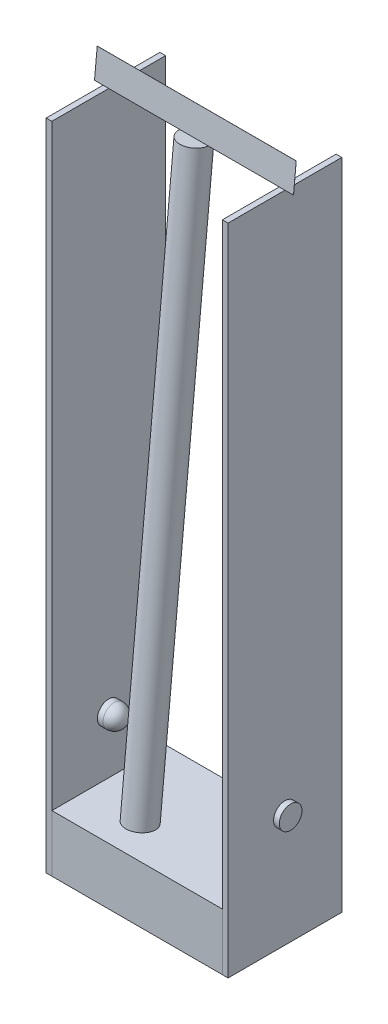
from build123d import *

# Parameters (mm, degrees)
SKETCH1_W                = 30
SKETCH1_H                = 20
BOSS_EXTRUDE1_DEPTH      = 10
SKETCH2_W                = 20
SKETCH2_H                = 115
BOSS_EXTRUDE2_DEPTH      = 1
SKETCH3_R                = 2
BOSS_EXTRUDE6_DEPTH      = 1
BOSS_EXTRUDE6_DEPTH_BACK = 4
FILLET1_R                = 2
SKETCH6_W                = 35
SKETCH6_H                = 5
BOSS_EXTRUDE3_DEPTH      = 0.01
SKETCH7_R                = 2.5
BOSS_EXTRUDE5_DEPTH      = 100
SKETCH8_R                = 2
CUT_EXTRUDE2_DEPTH       = 2.5
CUT_EXTRUDE2_DEPTH_BACK  = 34.5


with BuildPart() as part:
    # Sketch1 → Boss-Extrude1 (new body)
    with BuildSketch(Plane(origin=(0, 0, 0), x_dir=(1, 0, 0), z_dir=(0, 1, 0))):
        Rectangle(SKETCH1_W, SKETCH1_H)
    extrude(amount=BOSS_EXTRUDE1_DEPTH)


with BuildPart() as body_2:
    # Sketch2 → Boss-Extrude2 (new body)
    with BuildSketch(Plane.ZY.offset(15)):
        with Locations((0, 57.5)):
            Rectangle(SKETCH2_W, SKETCH2_H)
    extrude(amount=BOSS_EXTRUDE2_DEPTH)


with BuildPart() as body_3:
    # Sketch3 → Boss-Extrude6 (new body, two sides)
    with BuildSketch(Plane.ZY.offset(16)) as boss_extrude6_sk:
        with Locations((0, 20)):
            Circle(SKETCH3_R)
    extrude(amount=BOSS_EXTRUDE6_DEPTH)
    extrude(boss_extrude6_sk.sketch, amount=-BOSS_EXTRUDE6_DEPTH_BACK)

    # Fillet1
    fillet1_edges = [body_3.edges().sort_by_distance(p)[0] for p in [
        (-12, 20, -2),
    ]]
    fillet(fillet1_edges, radius=FILLET1_R)


with BuildPart() as body_4:
    # Mirror3: mirrored copy
    add(body_2.part.mirror(Plane(origin=(0, 0, 0), x_dir=(0, 0, 1), z_dir=(1, 0, 0))))


with BuildPart() as body_5:
    # Mirror3 2: mirrored copy
    add(body_3.part.mirror(Plane(origin=(0, 0, 0), x_dir=(0, 0, 1), z_dir=(1, 0, 0))))


with BuildPart() as body_6:
    # Sketch6 → Boss-Extrude3 (new body)
    with BuildSketch(Plane(origin=(0, 1.033707865, 10.853932584), x_dir=(-1, 0, 0), z_dir=(0, -0.094809093, -0.995495473))):
        with Locations((0, 116.981979348)):
            Rectangle(SKETCH6_W, SKETCH6_H)
    extrude(amount=BOSS_EXTRUDE3_DEPTH)

    # Sketch7 → Boss-Extrude5 (add)
    with BuildSketch(Plane(origin=(0, 113.966292135, -10.853932584), x_dir=(1, 0, 0), z_dir=(0, -0.995495473, 0.094809093))):
        with Locations((0, 10.893045652)):
            Circle(SKETCH7_R)
    extrude(amount=BOSS_EXTRUDE5_DEPTH)


with BuildPart() as cut_extrude2_tool:
    # Sketch8 → Cut-Extrude2 (new body, two sides)
    with BuildSketch(Plane.ZY.offset(16)) as cut_extrude2_sk:
        with Locations((0, 20)):
            Circle(SKETCH8_R)
    extrude(amount=CUT_EXTRUDE2_DEPTH)
    extrude(cut_extrude2_sk.sketch, amount=-CUT_EXTRUDE2_DEPTH_BACK)


with BuildPart() as body_2_1:
    add(body_2.part)

    # Cut-Extrude2: cut by cut_extrude2_tool
    add(cut_extrude2_tool.part, mode=Mode.SUBTRACT)


with BuildPart() as body_4_1:
    add(body_4.part)

    # Cut-Extrude2: cut by cut_extrude2_tool
    add(cut_extrude2_tool.part, mode=Mode.SUBTRACT)


solid = Compound([part.part, body_3.part, body_5.part, body_6.part, body_2_1.part, body_4_1.part])
